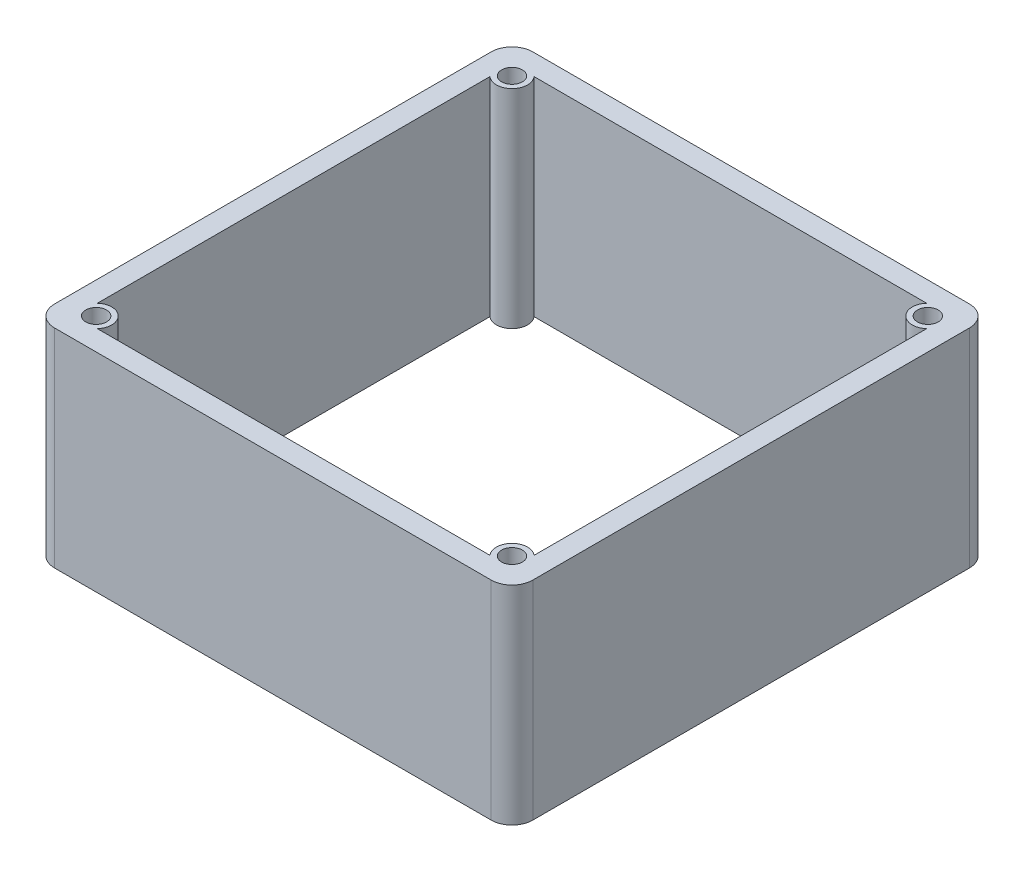
from build123d import *

# Parameters (mm, degrees)
SKETCH1_W           = 46
SKETCH1_H           = 46
SKETCH1_R           = 1
BOSS_EXTRUDE1_DEPTH = 20
FILLET1_R           = 2


with BuildPart() as part:
    # Sketch1 → Boss-Extrude1 (new body)
    with BuildSketch(Plane(origin=(0, 0, 0), x_dir=(1, 0, 0), z_dir=(0, 1, 0))):
        Rectangle(SKETCH1_W, SKETCH1_H)
        with Locations((-20, 20)):
            Circle(SKETCH1_R, mode=Mode.SUBTRACT)
        with Locations((20, 20)):
            Circle(SKETCH1_R, mode=Mode.SUBTRACT)
        with Locations((20, -20)):
            Circle(SKETCH1_R, mode=Mode.SUBTRACT)
        with Locations((-20, -20)):
            Circle(SKETCH1_R, mode=Mode.SUBTRACT)
        with BuildLine():
            Line((-18.881966011, 21), (18.881966011, 21))
            ThreePointArc((18.881966011, 21), (18.939339828, 18.939339828), (21, 18.881966011))
            Line((21, 18.881966011), (21, -18.881966011))
            ThreePointArc((21, -18.881966011), (18.939339828, -18.939339828), (18.881966011, -21))
            Line((18.881966011, -21), (-18.881966011, -21))
            ThreePointArc((-18.881966011, -21), (-18.939339828, -18.939339828), (-21, -18.881966011))
            Line((-21, -18.881966011), (-21, 18.881966011))
            ThreePointArc((-21, 18.881966011), (-18.939339828, 18.939339828), (-18.881966011, 21))
        make_face(mode=Mode.SUBTRACT)
    extrude(amount=BOSS_EXTRUDE1_DEPTH)

    # Fillet1
    fillet1_edges = [part.edges().sort_by_distance(p)[0] for p in [
        (23, 10, 23),
        (-23, 10, 23),
        (-23, 10, -23),
        (23, 10, -23),
    ]]
    fillet(fillet1_edges, radius=FILLET1_R)


solid = part.part
